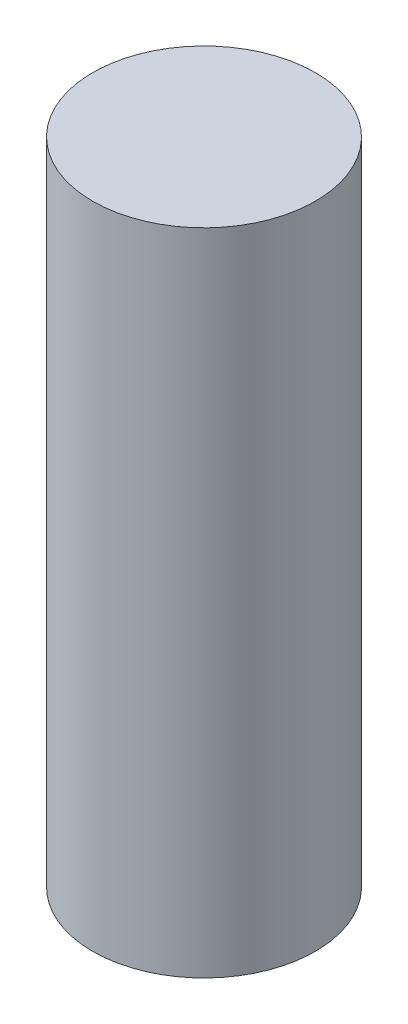
from build123d import *

# Parameters (mm, degrees)
SKETCH1_R           = 3
BOSS_EXTRUDE1_DEPTH = 17.5


with BuildPart() as part:
    # Sketch1 → Boss-Extrude1 (new body)
    with BuildSketch(Plane(origin=(0, 0, 0), x_dir=(1, 0, 0), z_dir=(0, 1, 0))):
        Circle(SKETCH1_R)
    extrude(amount=BOSS_EXTRUDE1_DEPTH)


solid = part.part
